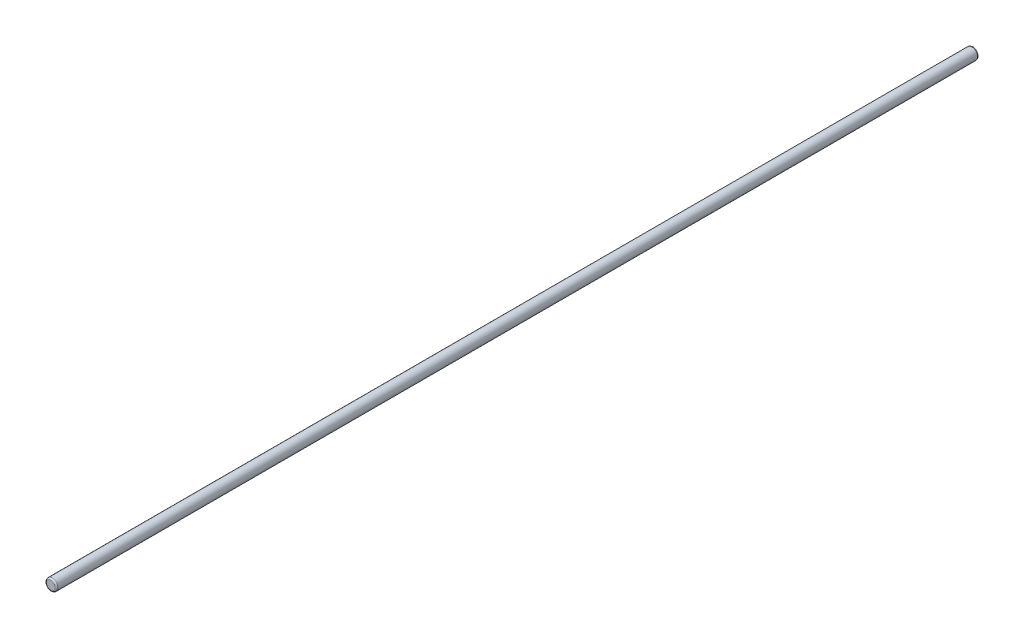
from build123d import *

# Parameters (mm, degrees)
EXTRUDE2_DEPTH      = 323.625
EXTRUDE2_DEPTH_BACK = 323.625
SKETCH1_R           = 4
FILLET2_R           = 1
FILLET3_R           = 1


with BuildPart() as part:
    # Sketch1 → Extrude2 (new, two sides: drawn at the far end of the back side and taken through both)
    with BuildSketch(Plane.XY.offset(-EXTRUDE2_DEPTH_BACK)):
        Circle(SKETCH1_R)
    extrude(amount=EXTRUDE2_DEPTH + EXTRUDE2_DEPTH_BACK)

    # Fillet2
    fillet2_edges = [part.edges().sort_by_distance(p)[0] for p in [
        (-4, 0, -323.625),
    ]]
    fillet(fillet2_edges, radius=FILLET2_R)

    # Fillet3
    fillet3_edges = [part.edges().sort_by_distance(p)[0] for p in [
        (-4, 0, 323.625),
    ]]
    fillet(fillet3_edges, radius=FILLET3_R)


solid = part.part
